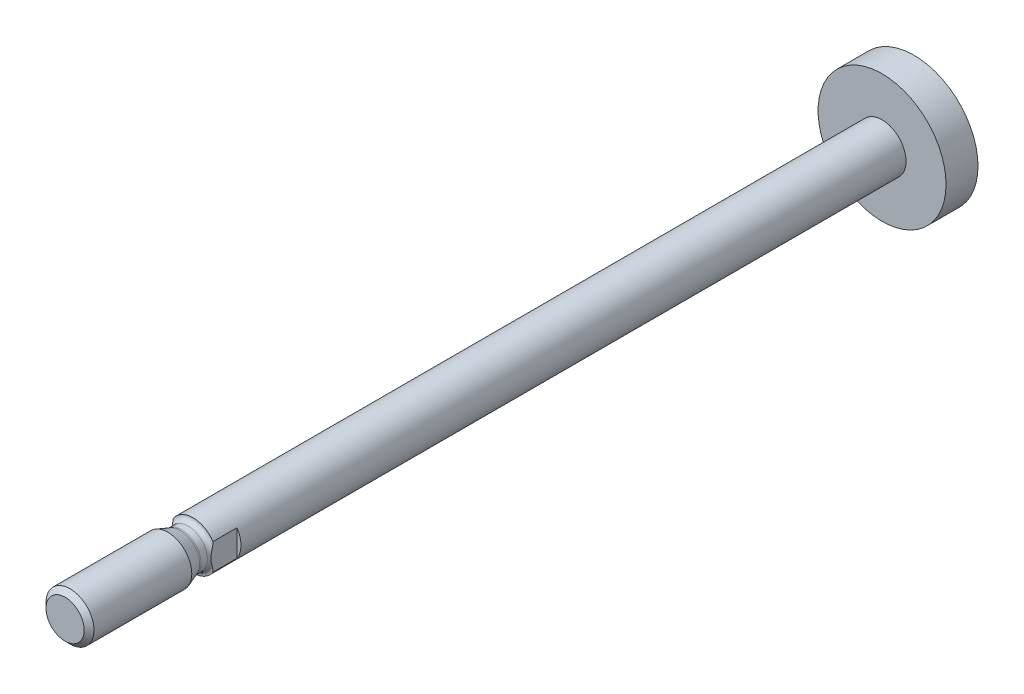
from build123d import *

# Parameters (mm, degrees)
CUT_EXTRUDE1_DEPTH = 4


with BuildPart() as part:
    # Sketch1 → Revolve1 (revolve)
    with BuildSketch(Plane(origin=(0, 0, 0), x_dir=(0, 0, -1), z_dir=(1, 0, 0))):
        Polygon((-5, 0), (-5, 3), (81.2, 3), (81.2, 8), (85.2, 8), (85.2, 0), align=None)
    revolve(axis=Axis((0, 0, -85.2), (0, 0, 1)))

    # Sketch2 → Revolve2 (revolve)
    with BuildSketch(Plane(origin=(0, 0, 0), x_dir=(0, 0, -1), z_dir=(1, 0, 0))):
        with BuildLine():
            Line((-21, 0), (-21, 2.3865))
            Line((-21, 2.3865), (-20.3865, 3))
            Line((-20.3865, 3), (-8.148486452, 3))
            Line((-8.148486452, 3), (-6.599415898, 2.436184428))
            ThreePointArc((-6.599415898, 2.436184428), (-6.498392718, 2.409115348), (-6.394203812, 2.4))
            Line((-6.394203812, 2.4), (-5.6, 2.4))
            ThreePointArc((-5.6, 2.4), (-5.175735931, 2.575735931), (-5, 3))
            Line((-5, 3), (-4, 3))
            Line((-4, 3), (-4, 0))
            Line((-4, 0), (-21, 0))
        make_face()
    revolve(axis=Axis((0, 0, 4), (0, 0, 1)))

    # Sketch3 → Cut-Extrude1 (cut)
    with BuildSketch(Plane.XY.offset(2)):
        Polygon((-5, 10), (-5, -5), (-2.5, -5), (-2.5, 5), (2.5, 5), (2.5, -5), (5, -5), (5, 10), align=None)
    extrude(amount=CUT_EXTRUDE1_DEPTH, mode=Mode.SUBTRACT)


solid = part.part
